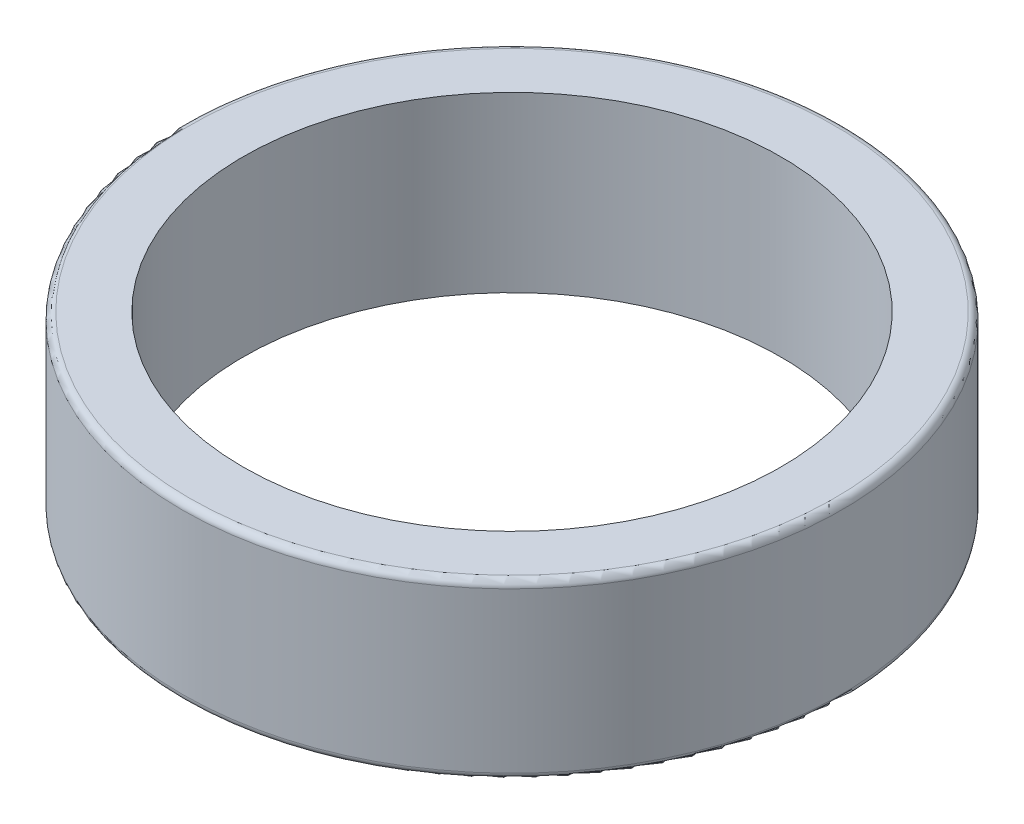
from build123d import *

# Parameters (mm, degrees)
SKETCH1_R           = 9.5
SKETCH1_R_2         = 7.75
BOSS_EXTRUDE1_DEPTH = 5
FILLET1_R           = 0.2


with BuildPart() as part:
    # Sketch1 → Boss-Extrude1 (new body)
    with BuildSketch(Plane(origin=(0, 0, 0), x_dir=(1, 0, 0), z_dir=(0, 1, 0))):
        Circle(SKETCH1_R)
        Circle(SKETCH1_R_2, mode=Mode.SUBTRACT)
    extrude(amount=BOSS_EXTRUDE1_DEPTH)

    # Fillet1
    fillet1_edges = [part.edges().sort_by_distance(p)[0] for p in [
        (-9.5, 0, 0),
        (-9.5, 5, 0),
    ]]
    fillet(fillet1_edges, radius=FILLET1_R)


solid = part.part
